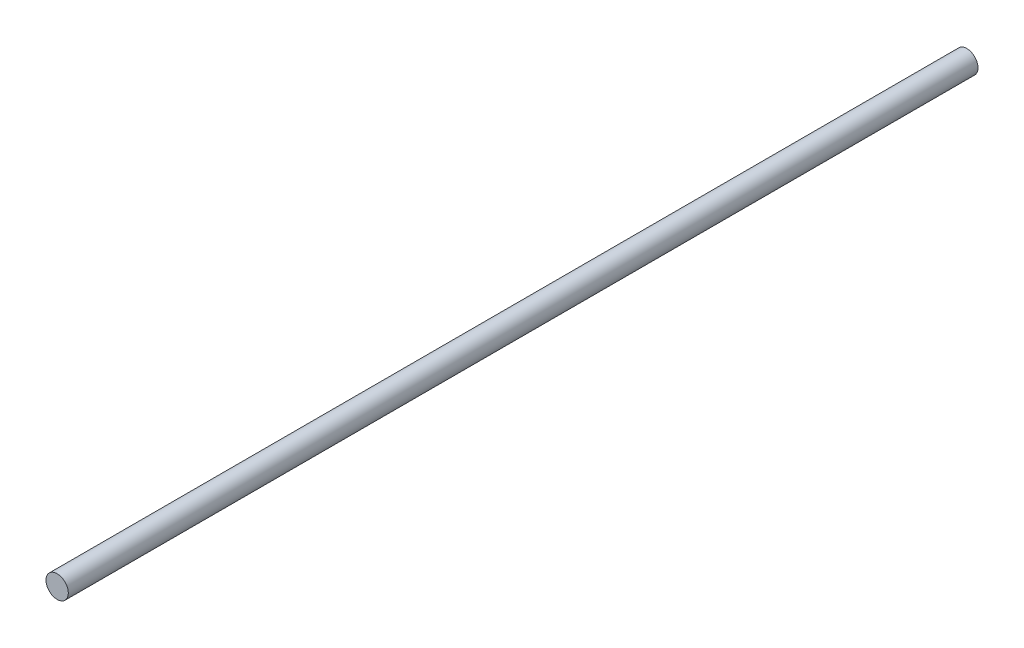
from build123d import *

# Parameters (mm, degrees)
SKETCH2_W = 325.847675392
SKETCH2_H = 4


with BuildPart() as part:
    # Sketch2 → Revolve1 (revolve)
    with BuildSketch(Plane(origin=(0, 0, 0), x_dir=(0, 0, -1), z_dir=(1, 0, 0))):
        with Locations((155.123837696, 2)):
            Rectangle(SKETCH2_W, SKETCH2_H)
    revolve(axis=Axis((0, 0, 7.8), (0, 0, -1)))


solid = part.part
